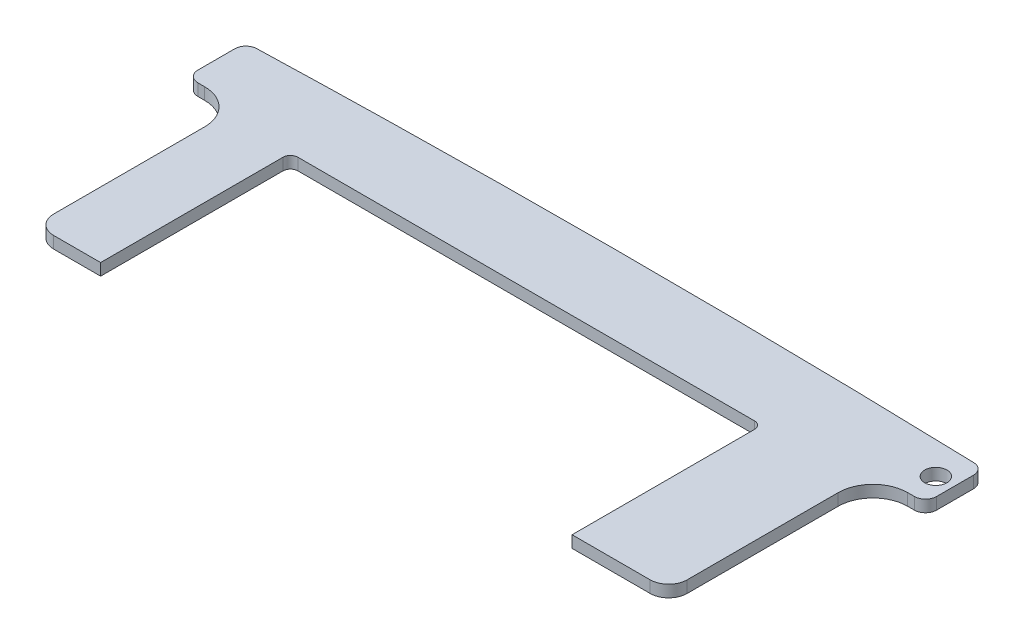
from build123d import *

# Parameters (mm, degrees)
SKETCH1_R           = 1.5
BOSS_EXTRUDE1_DEPTH = 1.6
FILLET1_R           = 1


with BuildPart() as part:
    # Sketch1 → Boss-Extrude1 (new body)
    with BuildSketch(Plane(origin=(0, 0, 0), x_dir=(1, 0, 0), z_dir=(0, 1, 0))):
        with BuildLine():
            Line((0.9, -3.8), (0, -3.8))
            ThreePointArc((0, -3.8), (-3.323401872, -5.176598128), (-4.7, -8.5))
            Line((-4.7, -8.5), (-4.7, -28.901853444))
            ThreePointArc((-4.7, -28.901853444), (-5.432233047, -30.669620397), (-7.2, -31.401853444))
            Line((-7.2, -31.401853444), (-17.75, -31.401853444))
            Line((-17.75, -31.401853444), (-17.75, -5.751853444))
            Line((-17.75, -5.751853444), (-81.45, -5.751853444))
            Line((-81.45, -5.751853444), (-81.45, -31.401853444))
            Line((-81.45, -31.401853444), (-87.8, -31.401853444))
            ThreePointArc((-87.8, -31.401853444), (-89.567766953, -30.669620397), (-90.3, -28.901853444))
            Line((-90.3, -28.901853444), (-90.3, -8.5))
            ThreePointArc((-90.3, -8.5), (-91.676598128, -5.176598128), (-95, -3.8))
            Line((-95, -3.8), (-95.9, -3.8))
            ThreePointArc((-95.9, -3.8), (-96.960660172, -3.360660172), (-97.4, -2.3))
            Line((-97.4, -2.3), (-97.4, 2.67635027))
            ThreePointArc((-97.4, 2.67635027), (-96.976459398, 3.720972291), (-95.94501978, 4.175674525))
            add(Edge.make_bspline(
                [(0.94501978, 4.175674525), (-47.5, 5.630319254), (-95.94501978, 4.175674525)],
                knots=[4.549425728, 4.549425728, 4.549425728, 4.875352233, 4.875352233, 4.875352233], degree=2, weights=[1, 0.98675085, 1]))
            ThreePointArc((0.94501978, 4.175674525), (1.976459398, 3.720972291), (2.4, 2.67635027))
            Line((2.4, 2.67635027), (2.4, -2.3))
            ThreePointArc((2.4, -2.3), (1.960660172, -3.360660172), (0.9, -3.8))
        make_face()
        Circle(SKETCH1_R, mode=Mode.SUBTRACT)
    extrude(amount=BOSS_EXTRUDE1_DEPTH)

    # Fillet1
    fillet1_edges = [part.edges().sort_by_distance(p)[0] for p in [
        (-17.75, 0.8, 5.751853444),
        (-81.45, 0.8, 5.751853444),
    ]]
    fillet(fillet1_edges, radius=FILLET1_R)


solid = part.part
